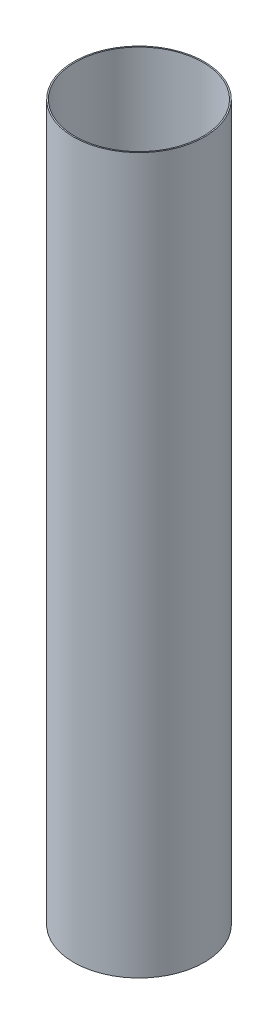
from build123d import *

# Parameters (mm, degrees)
SKETCH1_R           = 67.31
SKETCH1_R_2         = 66.04
BOSS_EXTRUDE1_DEPTH = 736.6


with BuildPart() as part:
    # Sketch1 → Boss-Extrude1 (new body)
    with BuildSketch(Plane(origin=(0, 0, 0), x_dir=(1, 0, 0), z_dir=(0, 1, 0))):
        Circle(SKETCH1_R)
        Circle(SKETCH1_R_2, mode=Mode.SUBTRACT)
    extrude(amount=BOSS_EXTRUDE1_DEPTH)


solid = part.part
